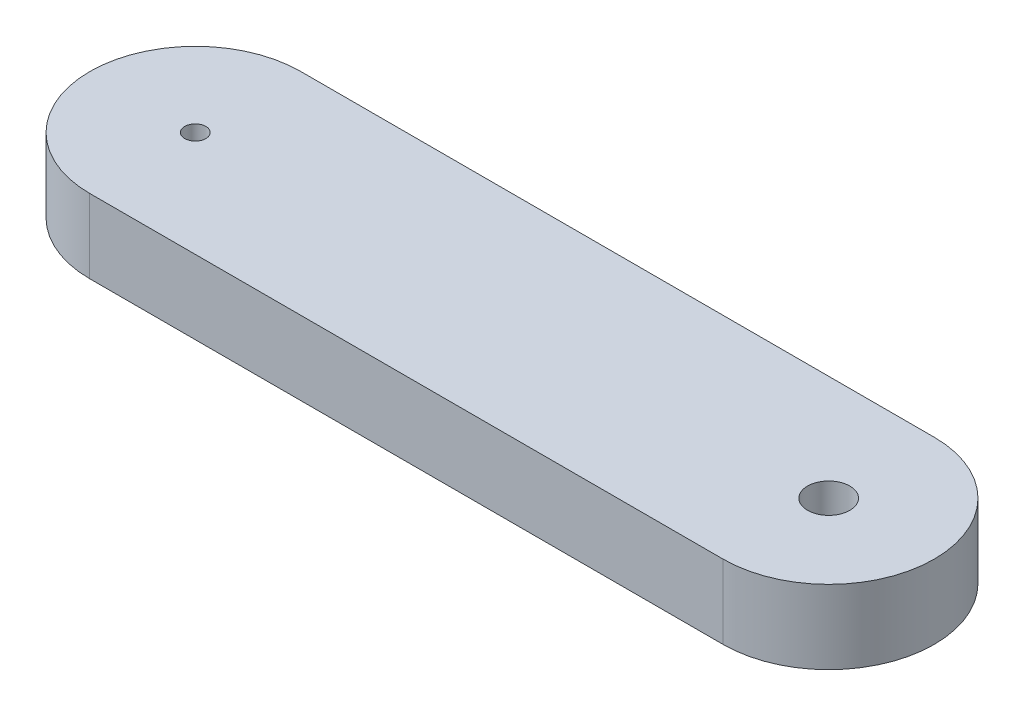
from build123d import *

# Parameters (mm, degrees)
BOSS_EXTRUDE1_DEPTH = 70
SKETCH2_R           = 10
CUT_EXTRUDE1_DEPTH  = 20
SKETCH3_R           = 20
CUT_EXTRUDE2_DEPTH  = 71


with BuildPart() as part:
    # Sketch1 → Boss-Extrude1 (new body)
    with BuildSketch(Plane(origin=(0, 0, 0), x_dir=(1, 0, 0), z_dir=(0, 1, 0))):
        with BuildLine():
            Line((0, 100), (600, 100))
            ThreePointArc((600, 100), (700, 0), (600, -100))
            Line((600, -100), (0, -100))
            ThreePointArc((0, -100), (-100, 0), (0, 100))
        make_face()
    extrude(amount=BOSS_EXTRUDE1_DEPTH)

    # Sketch2 → Cut-Extrude1 (cut)
    with BuildSketch(Plane(origin=(0, 70, 0), x_dir=(1, 0, 0), z_dir=(0, 1, 0))):
        Circle(SKETCH2_R)
    extrude(amount=-CUT_EXTRUDE1_DEPTH, mode=Mode.SUBTRACT)

    # Sketch3 → Cut-Extrude2 (cut, through all)
    with BuildSketch(Plane(origin=(0, 70, 0), x_dir=(1, 0, 0), z_dir=(0, 1, 0))):
        with Locations((600, 0)):
            Circle(SKETCH3_R)
    extrude(amount=-CUT_EXTRUDE2_DEPTH, mode=Mode.SUBTRACT)


solid = part.part
